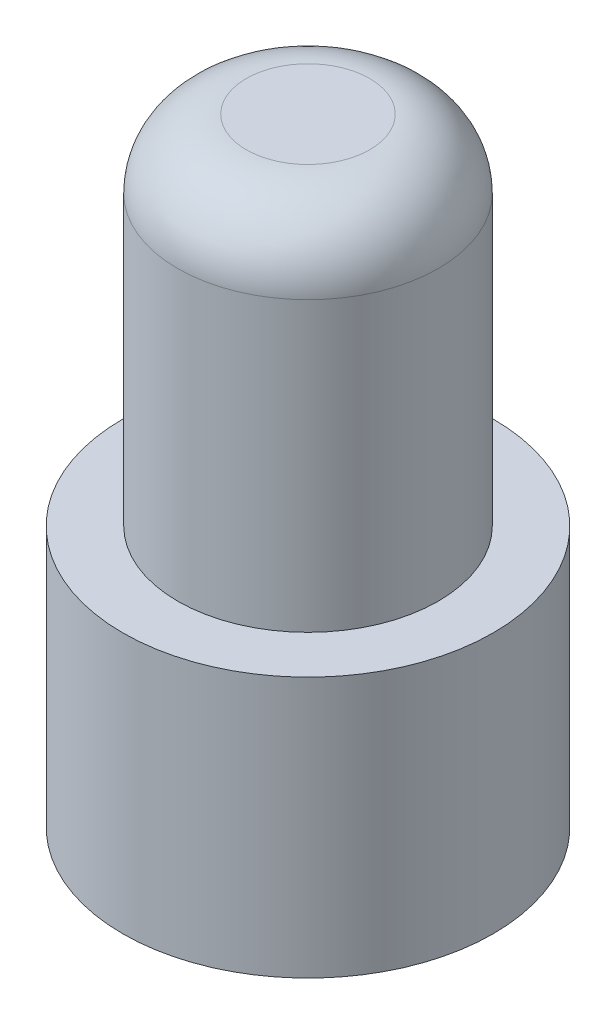
from build123d import *

# Parameters (mm, degrees)
FILETE1_R = 2.5


with BuildPart() as part:
    # Esboço1 → Revolução1 (revolve)
    with BuildSketch(Plane.XY):
        Polygon((-13.619087559, 0), (-13.619087559, 9.5), (-11.619087559, 9.5), (-11.619087559, 22.5), (-6.869087559, 22.5), (-6.869087559, 0), align=None)
    revolve(axis=Axis((-6.869087559, 0, 0), (0, 1, 0)))

    # Filete1
    filete1_edges = [part.edges().sort_by_distance(p)[0] for p in [
        (-2.119087559, 22.5, 0),
    ]]
    fillet(filete1_edges, radius=FILETE1_R)


solid = part.part
